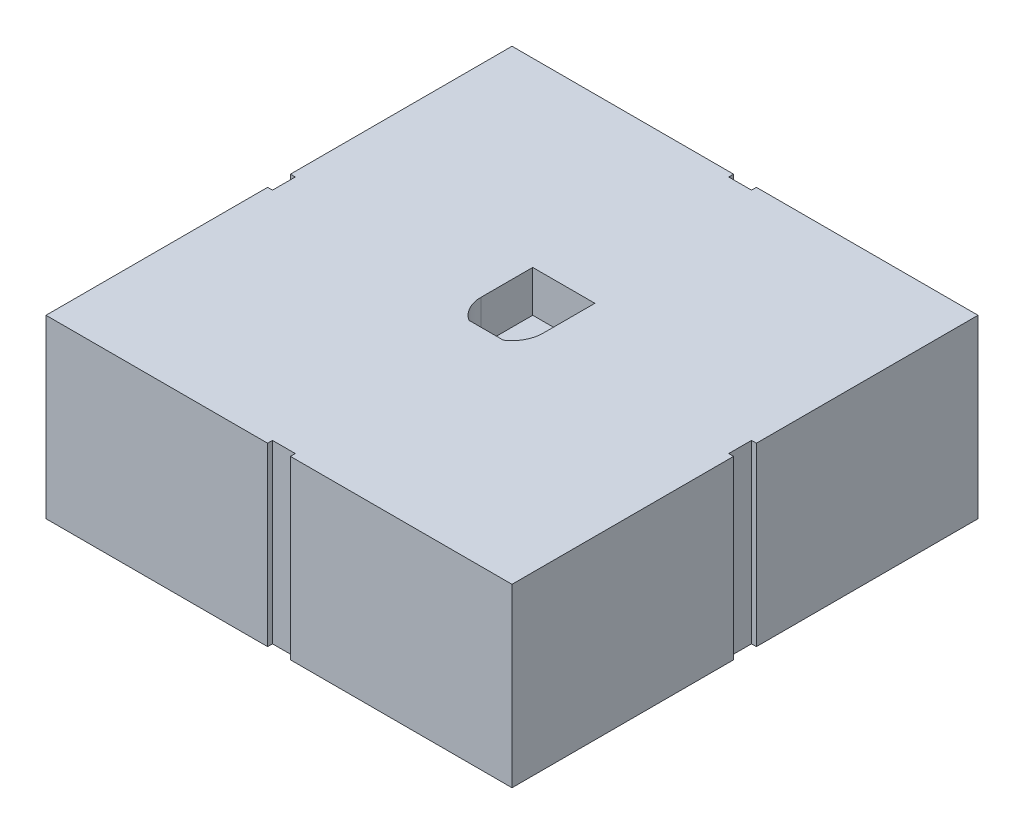
from build123d import *

# Parameters (mm, degrees)
SKETCH1_W           = 142.8
SKETCH1_H           = 142.8
BOSS_EXTRUDE1_DEPTH = 54
SKETCH2_W           = 10.53028371
SKETCH2_H           = 7.9375
CUT_EXTRUDE1_DEPTH  = 12.7
CUT_EXTRUDE5_DEPTH  = 210.044684218
CIRPATTERN3_COUNT   = 4


with BuildPart() as part:
    # Sketch1 → Boss-Extrude1 (new body)
    with BuildSketch(Plane(origin=(0, 0, 0), x_dir=(1, 0, 0), z_dir=(0, 1, 0))):
        with Locations((71.4, 71.4)):
            Rectangle(SKETCH1_W, SKETCH1_H)
    extrude(amount=BOSS_EXTRUDE1_DEPTH)

    # Sketch2 → Cut-Extrude1 (cut)
    with BuildSketch(Plane(origin=(0, 54, 0), x_dir=(1, 0, 0), z_dir=(0, 1, 0))):
        with BuildLine():
            ThreePointArc((76.665141855, 79.3375), (79.792737967, 75.904173), (80.925, 71.4))
            Line((80.925, 71.4), (80.925, 87.275))
            Line((80.925, 87.275), (61.875, 87.275))
            Line((61.875, 87.275), (61.875, 71.4))
            ThreePointArc((61.875, 71.4), (63.007262033, 75.904173), (66.134858145, 79.3375))
            ThreePointArc((66.134858145, 79.3375), (71.4, 80.925), (76.665141855, 79.3375))
        make_face()
        with BuildLine():
            ThreePointArc((76.665141855, 63.4625), (79.792737967, 66.895827), (80.925, 71.4))
            Line((80.925, 71.4), (76.665141855, 71.4))
            Line((76.665141855, 71.4), (76.665141855, 63.4625))
        make_face()
        with BuildLine():
            Line((76.665141855, 71.4), (80.925, 71.4))
            ThreePointArc((80.925, 71.4), (79.792737967, 75.904173), (76.665141855, 79.3375))
            Line((76.665141855, 79.3375), (76.665141855, 71.4))
        make_face()
        with BuildLine():
            Line((66.134858145, 63.4625), (66.134858145, 71.4))
            Line((66.134858145, 71.4), (61.875, 71.4))
            ThreePointArc((61.875, 71.4), (63.007262033, 66.895827), (66.134858145, 63.4625))
        make_face()
        with BuildLine():
            Line((61.875, 71.4), (66.134858145, 71.4))
            Line((66.134858145, 71.4), (66.134858145, 79.3375))
            ThreePointArc((66.134858145, 79.3375), (63.007262033, 75.904173), (61.875, 71.4))
        make_face()
        with Locations((71.4, 75.36875)):
            Rectangle(SKETCH2_W, SKETCH2_H)
        with BuildLine():
            Line((66.134858145, 79.3375), (76.665141855, 79.3375))
            ThreePointArc((76.665141855, 79.3375), (71.4, 80.925), (66.134858145, 79.3375))
        make_face()
        with BuildLine():
            ThreePointArc((76.665141855, 63.4625), (79.792737967, 66.895827), (80.925, 71.4))
            Line((80.925, 71.4), (76.665141855, 71.4))
            Line((76.665141855, 71.4), (76.665141855, 63.4625))
        make_face()
        with BuildLine():
            Line((76.665141855, 71.4), (80.925, 71.4))
            ThreePointArc((80.925, 71.4), (79.792737967, 75.904173), (76.665141855, 79.3375))
            Line((76.665141855, 79.3375), (76.665141855, 71.4))
        make_face()
        with BuildLine():
            Line((66.134858145, 63.4625), (66.134858145, 71.4))
            Line((66.134858145, 71.4), (61.875, 71.4))
            ThreePointArc((61.875, 71.4), (63.007262033, 66.895827), (66.134858145, 63.4625))
        make_face()
        with BuildLine():
            Line((61.875, 71.4), (66.134858145, 71.4))
            Line((66.134858145, 71.4), (66.134858145, 79.3375))
            ThreePointArc((66.134858145, 79.3375), (63.007262033, 75.904173), (61.875, 71.4))
        make_face()
        with Locations((71.4, 67.43125)):
            Rectangle(SKETCH2_W, SKETCH2_H)
    extrude(amount=-CUT_EXTRUDE1_DEPTH, mode=Mode.SUBTRACT)

    # Sketch7 → Cut-Extrude5 (cut, through all)
    with BuildSketch(Plane.XZ):
        Polygon((71.4, -142.8), (74.9, -142.8), (74.9, -141.3), (71.4, -141.3), (67.9, -141.3), (67.9, -142.8), align=None)
    cut_extrude5 = extrude(amount=-CUT_EXTRUDE5_DEPTH, mode=Mode.SUBTRACT)

    # CirPattern3: Cut-Extrude5 ×4 about axis
    cirpattern3_axis = Axis((71.4, 0, -71.4), (0, -1, 0))
    for i in range(1, CIRPATTERN3_COUNT):
        add(cut_extrude5.rotate(cirpattern3_axis, i * 360 / CIRPATTERN3_COUNT), mode=Mode.SUBTRACT)


solid = part.part
